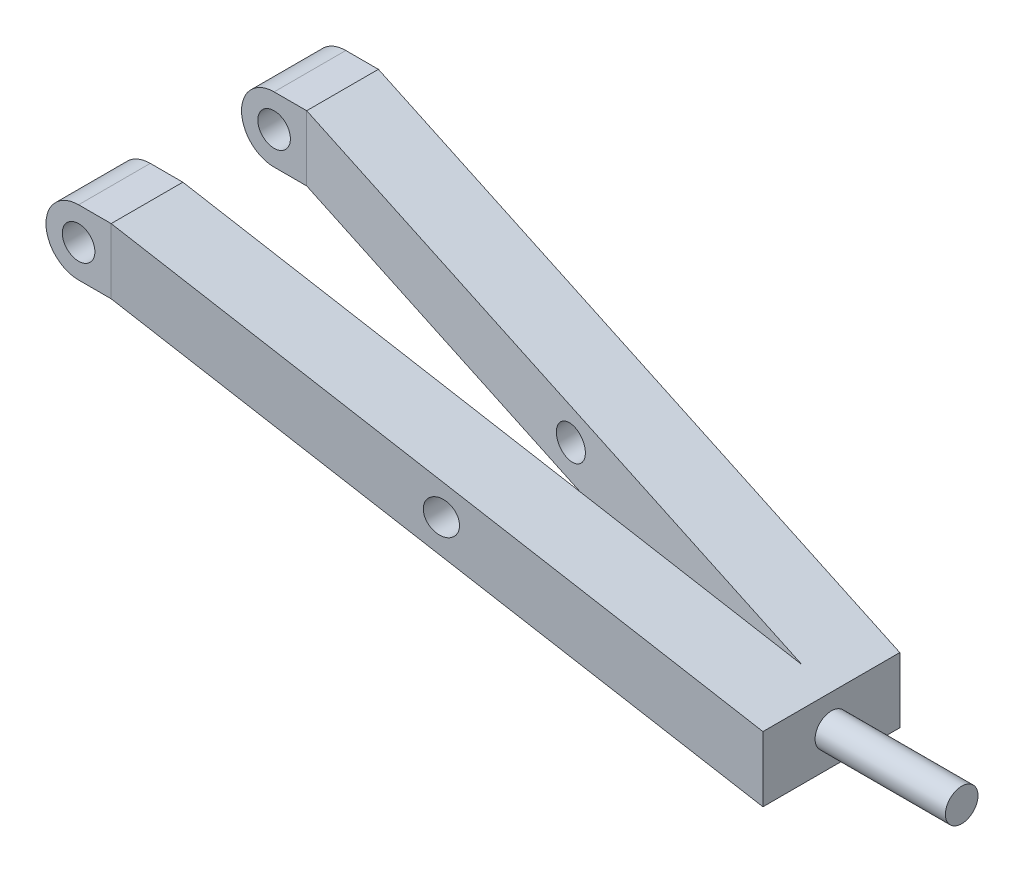
from build123d import *

# Parameters (mm, degrees)
SKETCH10_W              = 27.94
SKETCH10_H              = 25.4
SKETCH12_W              = 27.94
SKETCH12_H              = 25.4
BOSS_EXTRUDE2_DEPTH     = 25.4
SKETCH13_R              = 6.35
CUT_EXTRUDE4_DEPTH      = 105.14
CUT_EXTRUDE5_DEPTH      = 105.14
SKETCH15_R              = 6.35
BOSS_EXTRUDE3_DEPTH     = 50.8
SKETCH16_R              = 6.35
CUT_EXTRUDE6_DEPTH      = 53.07
CUT_EXTRUDE6_DEPTH_BACK = 53.07


with BuildPart() as part:
    # Sweep3: sweep along a curve in space
    with BuildLine() as sweep3_path:
        Line((12.7, 0, 38.1), (241.3, -69.85, 12.7))
    # Sketch10 → Sweep3 (sweep)
    with BuildSketch(Plane(origin=(12.7, 0, 0), x_dir=(0, 0, -1), z_dir=(1, 0, 0))):
        with Locations((-38.1, 0)):
            Rectangle(SKETCH10_W, SKETCH10_H)
    sweep3 = sweep(path=sweep3_path.line)

    # Sketch12 → Boss-Extrude2 (add)
    with BuildSketch(Plane(origin=(12.7, 0, 0), x_dir=(0, 0, -1), z_dir=(1, 0, 0))):
        with Locations((-38.1, 0)):
            Rectangle(SKETCH12_W, SKETCH12_H)
    boss_extrude2 = extrude(amount=-BOSS_EXTRUDE2_DEPTH)

    # Mirror5: Sweep3, Boss-Extrude2 across plane
    add(sweep3.mirror(Plane.XY))
    add(boss_extrude2.mirror(Plane.XY))

    # Sketch13 → Cut-Extrude4 (cut, through all)
    with BuildSketch(Plane(origin=(0, 0, -52.07), x_dir=(-1, 0, 0), z_dir=(0, 0, -1))):
        Circle(SKETCH13_R)
    extrude(amount=-CUT_EXTRUDE4_DEPTH, mode=Mode.SUBTRACT)

    # Sketch14 → Cut-Extrude5 (cut, through all)
    with BuildSketch(Plane(origin=(0, 0, -52.07), x_dir=(-1, 0, 0), z_dir=(0, 0, -1))):
        with BuildLine():
            Line((12.7, 12.7), (0, 12.7))
            ThreePointArc((0, 12.7), (8.980256121, 8.980256121), (12.7, 0))
            Line((12.7, 0), (12.7, 12.7))
        make_face()
    cut_extrude5 = extrude(amount=-CUT_EXTRUDE5_DEPTH, mode=Mode.SUBTRACT)

    # Mirror6: Cut-Extrude5 across plane
    add(cut_extrude5.mirror(Plane.ZX), mode=Mode.SUBTRACT)

    # Sketch15 → Boss-Extrude3 (add)
    with BuildSketch(Plane(origin=(241.3, 0, 0), x_dir=(0, 0, -1), z_dir=(1, 0, 0))):
        with Locations((0, -69.85)):
            Circle(SKETCH15_R)
    extrude(amount=BOSS_EXTRUDE3_DEPTH)

    # Sketch16 → Cut-Extrude6 (cut, two sides)
    with BuildSketch(Plane.XY) as cut_extrude6_sk:
        with Locations((128.524, -34.925)):
            Circle(SKETCH16_R)
    extrude(amount=CUT_EXTRUDE6_DEPTH, mode=Mode.SUBTRACT)
    extrude(cut_extrude6_sk.sketch, amount=-CUT_EXTRUDE6_DEPTH_BACK, mode=Mode.SUBTRACT)


solid = part.part
